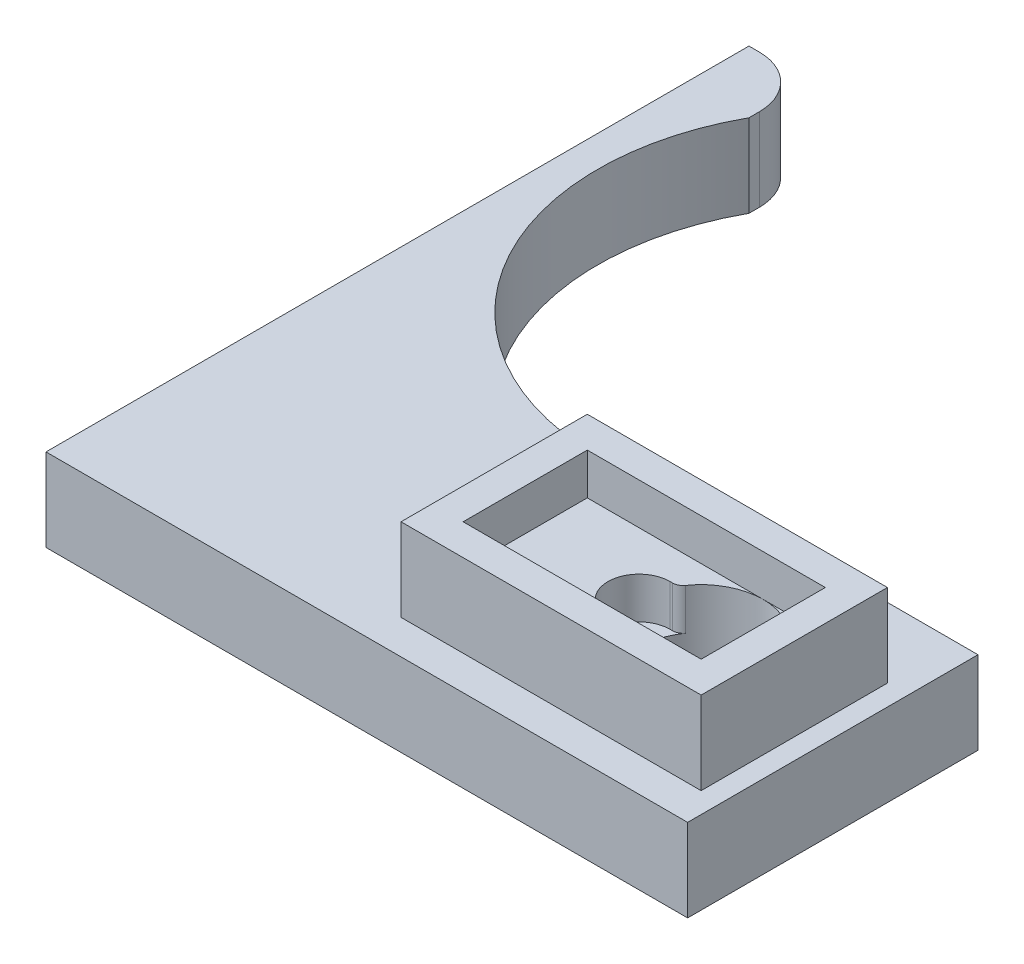
from build123d import *

# Parameters (mm, degrees)
ESQUISSE1_R             = 6
BOSS_EXTRU_1_DEPTH      = 8
ESQUISSE2_W             = 29
ESQUISSE2_H             = 18
BOSS_EXTRU_2_DEPTH      = 4
ESQUISSE3_W             = 29
ESQUISSE3_H             = 18
ESQUISSE3_W_2           = 23
ESQUISSE3_H_2           = 12
BOSS_EXTRU_3_DEPTH      = 4
ENL_V_MAT_EXTRU_1_DEPTH = 4


with BuildPart() as part:
    # Esquisse1 → Boss.-Extru.1 (new body)
    with BuildSketch(Plane(origin=(0, 0, 0), x_dir=(1, 0, 0), z_dir=(0, 1, 0))):
        with BuildLine():
            Line((0, 0), (6, 0))
            Line((6, 0), (36, 0))
            Line((36, 0), (62, 0))
            Line((62, 0), (62, 28.055987731))
            Line((62, 28.055987731), (36, 28.055987731))
            ThreePointArc((36, 28.055987731), (9.034681758, 34.39083629), (6, 61.923533231))
            Line((6, 61.923533231), (6, 62.923533231))
            ThreePointArc((6, 62.923533231), (4.535533906, 66.459067137), (1, 67.923533231))
            Line((1, 67.923533231), (0, 67.923533231))
            Line((0, 67.923533231), (0, 0))
        make_face()
        with Locations((51, 12.304583192)):
            Circle(ESQUISSE1_R, mode=Mode.SUBTRACT)
    extrude(amount=BOSS_EXTRU_1_DEPTH)

    # Esquisse2 → Boss.-Extru.2 (add)
    with BuildSketch(Plane(origin=(0, 8, 0), x_dir=(1, 0, 0), z_dir=(0, 1, 0))):
        with Locations((45.5, 12.304583192)):
            Rectangle(ESQUISSE2_W, ESQUISSE2_H)
        with BuildLine():
            Line((45, 15.304583192), (45.255437353, 15.304583192))
            ThreePointArc((45.255437353, 15.304583192), (45.718347403, 15.418177932), (46.07608916, 15.733154621))
            ThreePointArc((46.07608916, 15.733154621), (57, 12.304583192), (46.07608916, 8.876011764))
            ThreePointArc((46.07608916, 8.876011764), (45.718347403, 9.190988453), (45.255437353, 9.304583192))
            Line((45.255437353, 9.304583192), (45, 9.304583192))
            ThreePointArc((45, 9.304583192), (42, 12.304583192), (45, 15.304583192))
        make_face(mode=Mode.SUBTRACT)
    extrude(amount=BOSS_EXTRU_2_DEPTH)

    # Esquisse3 → Boss.-Extru.3 (add)
    with BuildSketch(Plane(origin=(0, 12, 0), x_dir=(1, 0, 0), z_dir=(0, 1, 0))):
        with Locations((45.5, 12.304583192)):
            Rectangle(ESQUISSE3_W, ESQUISSE3_H)
        with Locations((45.5, 12.304583192)):
            Rectangle(ESQUISSE3_W_2, ESQUISSE3_H_2, mode=Mode.SUBTRACT)
    extrude(amount=BOSS_EXTRU_3_DEPTH)

    # Esquisse4 → Enlèv. mat.-Extru.1 (cut)
    with BuildSketch(Plane.XZ):
        Polygon((47.7, -17.055987731), (54.3, -17.055987731), (55.193703609, -16.162284122), (57.721788353, -28.055987731), (54.3, -28.055987731), (47.7, -28.055987731), (44.278211647, -28.055987731), (46.806296391, -16.162284122), align=None)
    extrude(amount=-ENL_V_MAT_EXTRU_1_DEPTH, mode=Mode.SUBTRACT)


solid = part.part
